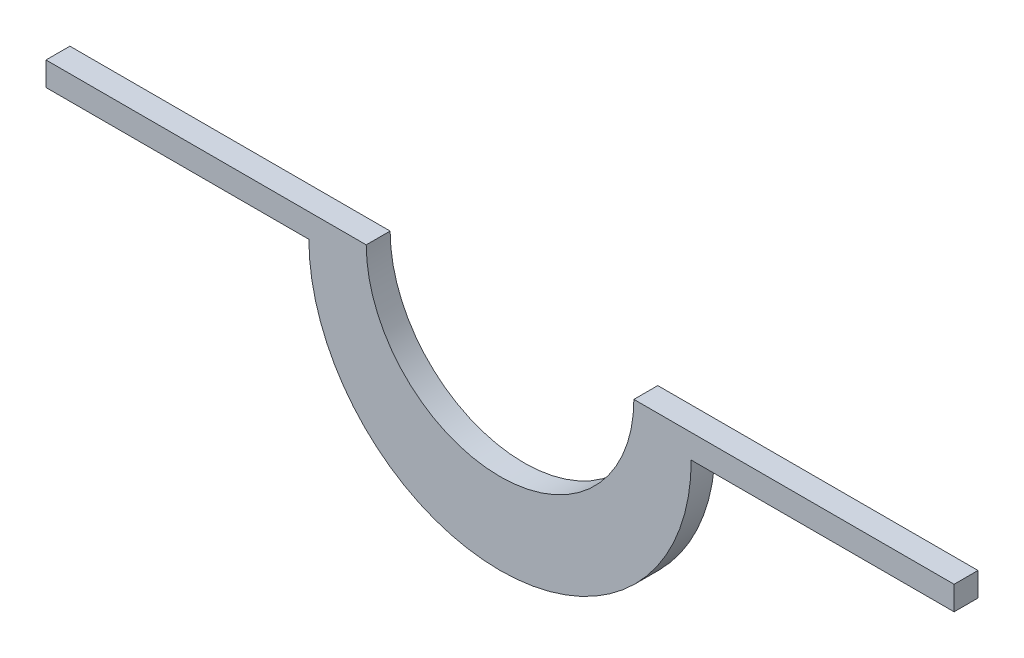
from build123d import *

# Parameters (mm, degrees)
BOSS_EXTRU_1_DEPTH = 10


with BuildPart() as part:
    # Esquisse1 → Boss.-Extru.1 (new body)
    with BuildSketch(Plane.XY):
        with BuildLine():
            Line((0, 0), (134, 0))
            ThreePointArc((134, 0), (190, -56), (246, 0))
            Line((246, 0), (380, 0))
            Line((380, 0), (380, -10))
            Line((380, -10), (270, -10))
            ThreePointArc((270, -10), (190, -90), (110, -10))
            Line((110, -10), (0, -10))
            Line((0, -10), (0, 0))
        make_face()
    extrude(amount=BOSS_EXTRU_1_DEPTH)


solid = part.part
